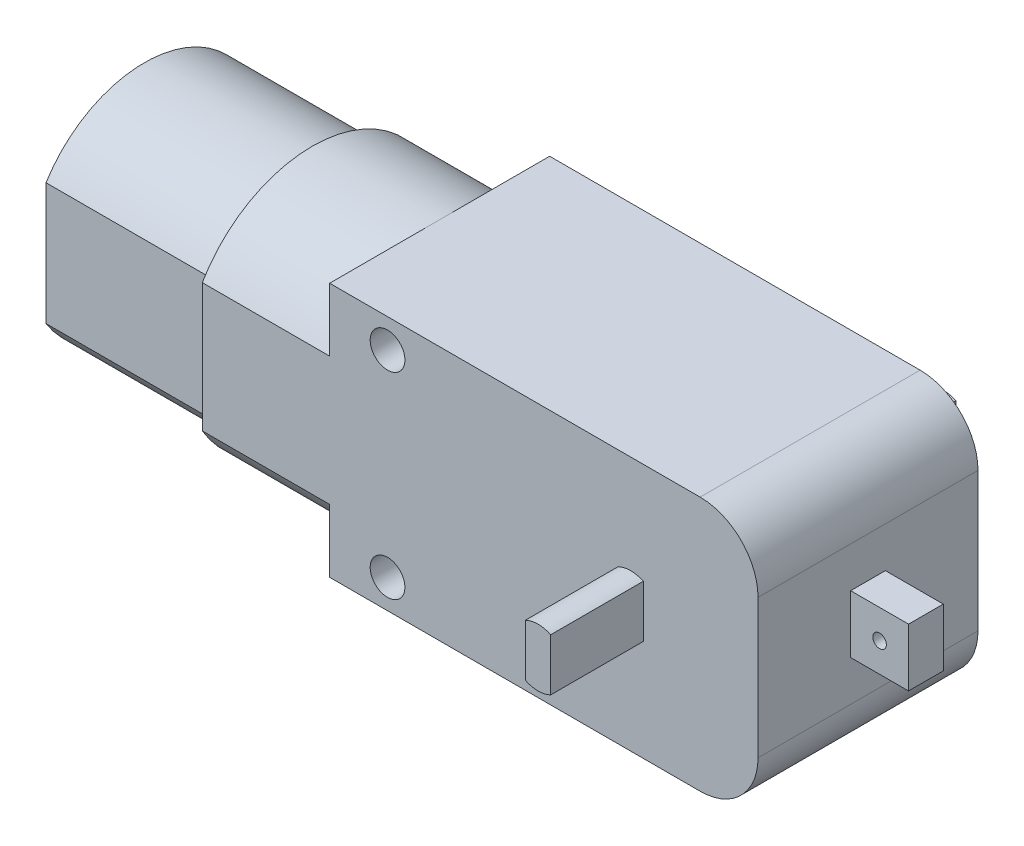
from build123d import *

# Parameters (mm, degrees)
SKETCH1_R                = 1.5
BOSS_EXTRUDE1_DEPTH      = 19
SKETCH2_W                = 3
SKETCH2_H                = 5
BOSS_EXTRUDE2_DEPTH      = 5
SKETCH3_R                = 0.584411026
CUT_EXTRUDE1_DEPTH       = 5
BOSS_EXTRUDE3_DEPTH      = 8
BOSS_EXTRUDE3_DEPTH_BACK = 27
BOSS_EXTRUDE4_DEPTH      = 11
BOSS_EXTRUDE5_DEPTH      = 8.5
BOSS_EXTRUDE6_DEPTH      = 6


with BuildPart() as part:
    # Sketch1 → Boss-Extrude1 (new body)
    with BuildSketch(Plane.XY):
        with BuildLine():
            Line((-18.5, -11), (13.5, -11))
            ThreePointArc((13.5, -11), (17.035533906, -9.535533906), (18.5, -6))
            Line((18.5, -6), (18.5, 6))
            ThreePointArc((18.5, 6), (17.035533906, 9.535533906), (13.5, 11))
            Line((13.5, 11), (-18.5, 11))
            Line((-18.5, 11), (-18.5, -11))
        make_face()
        with Locations((-13.5, 8.5)):
            Circle(SKETCH1_R, mode=Mode.SUBTRACT)
        with Locations((-13.5, -8.5)):
            Circle(SKETCH1_R, mode=Mode.SUBTRACT)
    extrude(amount=BOSS_EXTRUDE1_DEPTH)

    # Sketch2 → Boss-Extrude2 (add)
    with BuildSketch(Plane(origin=(18.5, 0, 0), x_dir=(0, 0, -1), z_dir=(1, 0, 0))):
        with Locations((-9.5, 0)):
            Rectangle(SKETCH2_W, SKETCH2_H)
    extrude(amount=BOSS_EXTRUDE2_DEPTH)

    # Sketch3 → Cut-Extrude1 (cut)
    with BuildSketch(Plane.XY.offset(11)):
        with Locations((21, 0)):
            Circle(SKETCH3_R)
    extrude(amount=-CUT_EXTRUDE1_DEPTH, mode=Mode.SUBTRACT)

    # Sketch4 → Boss-Extrude3 (add, two sides)
    with BuildSketch(Plane.XY.offset(19)) as boss_extrude3_sk:
        with BuildLine():
            Line((8.589724736, 2.25), (8.589724736, -2.25))
            ThreePointArc((8.589724736, -2.25), (7.5, -2.5), (6.410275264, -2.25))
            Line((6.410275264, -2.25), (6.410275264, 2.25))
            ThreePointArc((6.410275264, 2.25), (7.5, 2.5), (8.589724736, 2.25))
        make_face()
    extrude(amount=BOSS_EXTRUDE3_DEPTH)
    extrude(boss_extrude3_sk.sketch, amount=-BOSS_EXTRUDE3_DEPTH_BACK)

    # Sketch5 → Boss-Extrude4 (add)
    with BuildSketch(Plane.ZY.offset(18.5)):
        with BuildLine():
            ThreePointArc((9.500000028, 11), (4.022680904, 9.539338317), (0, 5.545268253))
            Line((0, 5.545268253), (0, -5.545268253))
            ThreePointArc((0, -5.545268253), (4.022680873, -9.539338299), (9.499999955, -11))
            ThreePointArc((9.499999955, -11), (14.977319088, -9.539338321), (19, -5.545268253))
            Line((19, -5.545268253), (19, 5.545268253))
            ThreePointArc((19, 5.545268253), (14.97731912, 9.539338303), (9.500000028, 11))
        make_face()
    extrude(amount=BOSS_EXTRUDE4_DEPTH)

    # Sketch6 → Boss-Extrude5 (add)
    with BuildSketch(Plane.ZY.offset(29.5)):
        with BuildLine():
            Line((1, 5.267826876), (1, -5.267826876))
            ThreePointArc((1, -5.267826876), (9.5, -10), (18, -5.267826876))
            Line((18, -5.267826876), (18, 5.267826876))
            ThreePointArc((18, 5.267826876), (9.5, 10), (1, 5.267826876))
        make_face()
    extrude(amount=BOSS_EXTRUDE5_DEPTH)

    # Sketch7 → Boss-Extrude6 (add)
    with BuildSketch(Plane.ZY.offset(38)):
        with BuildLine():
            ThreePointArc((1, -5.267826876), (9.5, -10), (18, -5.267826876))
            Line((18, -5.267826876), (18, 5.267826876))
            ThreePointArc((18, 5.267826876), (9.5, 10), (1, 5.267826876))
            Line((1, 5.267826876), (1, -5.267826876))
        make_face()
    extrude(amount=BOSS_EXTRUDE6_DEPTH)


solid = part.part
